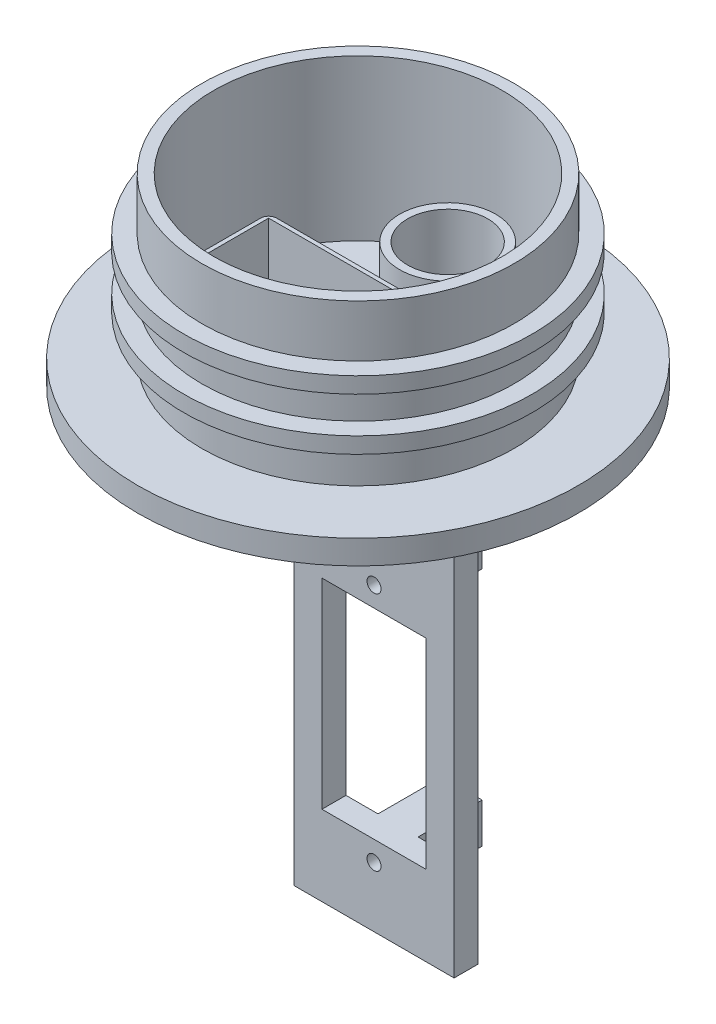
from build123d import *

# Parameters (mm, degrees)
SKETCH_1_R               = 19.5
SKETCH_1_R_2             = 18
EXTRUDE_1_DEPTH          = 20
SKETCH_3_R               = 27.5
EXTRUDE_2_DEPTH          = 3
SKETCH_10_R              = 6
SKETCH_10_R_2            = 5
EXTRUDE_6_DEPTH          = 10
SKETCH_11_R              = 5.007506695
CUT_EXTRUDE_4_DEPTH      = 19
CUT_EXTRUDE_4_DEPTH_BACK = 10
SKETCH_15_W              = 20
SKETCH_15_H              = 60
SKETCH_15_W_2            = 13
SKETCH_15_H_2            = 25
EXTRUDE_7_DEPTH          = 1
EXTRUDE_7_DEPTH_BACK     = 2
SKETCH_16_W              = 5
SKETCH_16_H              = 5
EXTRUDE_8_DEPTH          = 10
SKETCH_18_R              = 0.875
CUT_EXTRUDE_5_DEPTH      = 10
CUT_EXTRUDE_5_DEPTH_BACK = 39
SKETCH_12_W              = 21.5
SKETCH_12_H              = 13
CUT_EXTRUDE_6_DEPTH      = 21.5
SKETCH_19_W              = 22.5
SKETCH_19_H              = 14
SKETCH_19_W_2            = 21.5
SKETCH_19_H_2            = 13
EXTRUDE_9_DEPTH          = 10
FILLET_2_R               = 1
FILLET_3_R               = 1
FILLET_4_R               = 1
FILLET_5_R               = 1
SKETCH_25_R              = 21.75
SKETCH_25_R_2            = 19.5
EXTRUDE_12_DEPTH         = 2
EXTRUDE_START            = -1
SKETCH_26_R              = 21.75
SKETCH_26_R_2            = 19.5
EXTRUDE_13_DEPTH         = 2


with BuildPart() as part:
    # 草圖1 → 填料-伸長1 (new body)
    with BuildSketch(Plane(origin=(0, 0, 0), x_dir=(1, 0, 0), z_dir=(0, 1, 0))):
        Circle(SKETCH_1_R)
        Circle(SKETCH_1_R_2, mode=Mode.SUBTRACT)
    extrude(amount=EXTRUDE_1_DEPTH)

    # 草圖3 → 填料-伸長2 (add)
    with BuildSketch(Plane.XZ):
        Circle(SKETCH_3_R)
    extrude(amount=EXTRUDE_2_DEPTH)

    # 草圖10 → 填料-伸長6 (add)
    with BuildSketch(Plane(origin=(0, -3, 0), x_dir=(-1, 0, 0), z_dir=(0, -1, 0))):
        with Locations((0, 11.196036894)):
            Circle(SKETCH_10_R)
        with Locations((0, 11.196036894)):
            Circle(SKETCH_10_R_2, mode=Mode.SUBTRACT)
    extrude(amount=-EXTRUDE_6_DEPTH)

    # 草圖11 → 除料-伸長4 (cut, two sides)
    with BuildSketch(Plane(origin=(0, -3, 0), x_dir=(-1, 0, 0), z_dir=(0, -1, 0))) as cut_extrude_4_sk:
        with Locations((0, 11.196036894)):
            Circle(SKETCH_11_R)
    extrude(amount=CUT_EXTRUDE_4_DEPTH, mode=Mode.SUBTRACT)
    extrude(cut_extrude_4_sk.sketch, amount=-CUT_EXTRUDE_4_DEPTH_BACK, mode=Mode.SUBTRACT)

    # 草圖15 → 填料-伸長7 (add, two sides)
    with BuildSketch(Plane.XY.offset(-3)) as extrude_7_sk:
        with Locations((0, -33)):
            Rectangle(SKETCH_15_W, SKETCH_15_H)
        with Locations((0, -40.5)):
            Rectangle(SKETCH_15_W_2, SKETCH_15_H_2, mode=Mode.SUBTRACT)
    extrude(amount=EXTRUDE_7_DEPTH)
    extrude(extrude_7_sk.sketch, amount=-EXTRUDE_7_DEPTH_BACK)

    # 草圖16 → 填料-伸長8 (add)
    with BuildSketch(Plane.XY.offset(-3)):
        with Locations((0, -25.5)):
            Rectangle(SKETCH_16_W, SKETCH_16_H)
        with Locations((0, -55.5)):
            Rectangle(SKETCH_16_W, SKETCH_16_H)
    extrude(amount=-EXTRUDE_8_DEPTH)

    # 草圖18 → 除料-伸長5 (cut, two sides)
    with BuildSketch(Plane.XY) as cut_extrude_5_sk:
        with Locations((0, -55.5)):
            Circle(SKETCH_18_R)
        with Locations((0, -25.5)):
            Circle(SKETCH_18_R)
    extrude(amount=CUT_EXTRUDE_5_DEPTH, mode=Mode.SUBTRACT)
    extrude(cut_extrude_5_sk.sketch, amount=-CUT_EXTRUDE_5_DEPTH_BACK, mode=Mode.SUBTRACT)

    # 草圖12 → 除料-伸長6 (cut)
    with BuildSketch(Plane.XZ.offset(3)):
        with Locations((0, 6.907998134)):
            Rectangle(SKETCH_12_W, SKETCH_12_H)
    extrude(amount=-CUT_EXTRUDE_6_DEPTH, mode=Mode.SUBTRACT)

    # 草圖19 → 填料-伸長9 (add)
    with BuildSketch(Plane(origin=(0, 0, 0), x_dir=(1, 0, 0), z_dir=(0, 1, 0))):
        with Locations((0, -6.907998134)):
            Rectangle(SKETCH_19_W, SKETCH_19_H)
        with Locations((0, -6.907998134)):
            Rectangle(SKETCH_19_W_2, SKETCH_19_H_2, mode=Mode.SUBTRACT)
    extrude(amount=EXTRUDE_9_DEPTH)

    # 圓角2
    fillet_2_edges = [part.edges().sort_by_distance(p)[0] for p in [
        (-11.25, 5, -0.092001866),
    ]]
    fillet(fillet_2_edges, radius=FILLET_2_R)

    # 圓角3
    fillet_3_edges = [part.edges().sort_by_distance(p)[0] for p in [
        (11.25, 5, -0.092001866),
    ]]
    fillet(fillet_3_edges, radius=FILLET_3_R)

    # 圓角4
    fillet_4_edges = [part.edges().sort_by_distance(p)[0] for p in [
        (11.25, 5, 13.907998134),
    ]]
    fillet(fillet_4_edges, radius=FILLET_4_R)

    # 圓角5
    fillet_5_edges = [part.edges().sort_by_distance(p)[0] for p in [
        (-11.25, 5, 13.907998134),
    ]]
    fillet(fillet_5_edges, radius=FILLET_5_R)

    # 草圖25 → 填料-伸長12 (add)
    with BuildSketch(Plane(origin=(0, 7, 0), x_dir=(-1, 0, 0), z_dir=(0, -1, 0))):
        Circle(SKETCH_25_R)
        Circle(SKETCH_25_R_2, mode=Mode.SUBTRACT)
    extrude(amount=EXTRUDE_12_DEPTH)

    # 草圖26 → 填料-伸長13 (add)
    with BuildSketch(Plane(origin=(0, 10.5, 0), x_dir=(-1, 0, 0), z_dir=(0, -1, 0)).offset(EXTRUDE_START)):
        Circle(SKETCH_26_R)
        Circle(SKETCH_26_R_2, mode=Mode.SUBTRACT)
    extrude(amount=-EXTRUDE_13_DEPTH)


solid = part.part
